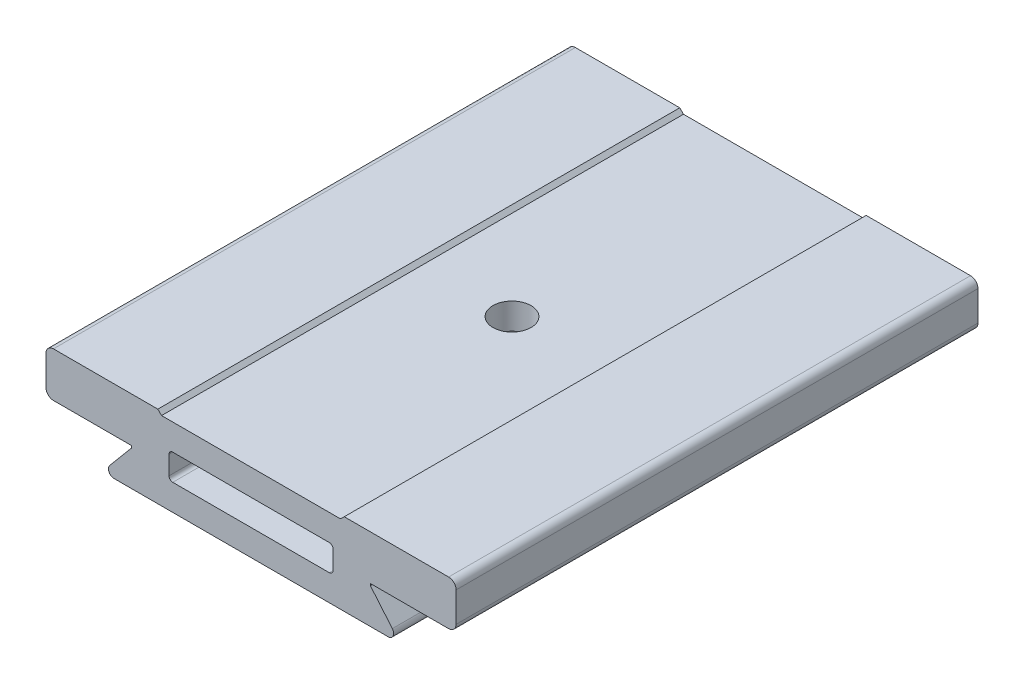
from build123d import *

# Parameters (mm, degrees)
SKETCH1_W           = 55
SKETCH1_H           = 11
BOSS_EXTRUDE1_DEPTH = 35
CUT_EXTRUDE1_DEPTH  = 71
FILLET1_R           = 1
CUT_EXTRUDE2_DEPTH  = 71
CUT_EXTRUDE3_DEPTH  = 71
CUT_EXTRUDE4_DEPTH  = 7
FILLET2_R           = 0.5
SKETCH6_R           = 2.5527
CUT_EXTRUDE5_DEPTH  = 5


with BuildPart() as part:
    # Sketch1 → Boss-Extrude1 (new body, symmetric)
    with BuildSketch(Plane.XY):
        Rectangle(SKETCH1_W, SKETCH1_H)
    extrude(amount=BOSS_EXTRUDE1_DEPTH, both=True)

    # Sketch2 → Cut-Extrude1 (cut, through all)
    with BuildSketch(Plane.XY.offset(35)):
        with BuildLine():
            Line((-27.5, -0.5), (-16, -0.5))
            Line((-16, -0.5), (-16, -0.75))
            Line((-16, -0.75), (-18.95187639, -4.267909293))
            ThreePointArc((-18.95187639, -4.267909293), (-19.057073898, -5.066963696), (-18.377343058, -5.5))
            Line((-18.377343058, -5.5), (-27.5, -5.5))
            Line((-27.5, -5.5), (-27.5, -0.5))
        make_face()
    cut_extrude1 = extrude(amount=-CUT_EXTRUDE1_DEPTH, mode=Mode.SUBTRACT)

    # Mirror1: Cut-Extrude1 across plane
    add(cut_extrude1.mirror(Plane(origin=(0, 0, 0), x_dir=(0, 0, 1), z_dir=(1, 0, 0))), mode=Mode.SUBTRACT)

    # Fillet1
    fillet1_edges = [part.edges().sort_by_distance(p)[0] for p in [
        (-27.5, -0.5, 0),
        (27.5, -0.5, 0),
        (-27.5, 5.5, 0),
        (27.5, 5.5, 0),
    ]]
    fillet(fillet1_edges, radius=FILLET1_R)

    # Sketch3 → Cut-Extrude2 (cut, through all)
    with BuildSketch(Plane.XY.offset(35)):
        Polygon((-12.5, 5.5), (0, 5.5), (0, 5), (-12, 5), align=None)
    cut_extrude2 = extrude(amount=-CUT_EXTRUDE2_DEPTH, mode=Mode.SUBTRACT)

    # Mirror2: Cut-Extrude2 across plane
    add(cut_extrude2.mirror(Plane(origin=(0, 0, 0), x_dir=(0, 0, 1), z_dir=(1, 0, 0))), mode=Mode.SUBTRACT)

    # Sketch4 → Cut-Extrude3 (cut, through all)
    with BuildSketch(Plane.XY.offset(35)):
        with BuildLine():
            Line((-11, 1.5), (11, 1.5))
            Line((11, 1.5), (11, -1.5))
            ThreePointArc((11, -1.5), (10.853553391, -1.853553391), (10.5, -2))
            Line((10.5, -2), (-10.5, -2))
            ThreePointArc((-10.5, -2), (-10.853553391, -1.853553391), (-11, -1.5))
            Line((-11, -1.5), (-11, 1.5))
        make_face()
    extrude(amount=-CUT_EXTRUDE3_DEPTH, mode=Mode.SUBTRACT)

    # Sketch5 → Cut-Extrude4 (cut)
    with BuildSketch(Plane.XZ.offset(5.5)):
        with BuildLine():
            Line((-8, 28.5), (8, 28.5))
            ThreePointArc((8, 28.5), (10.121320344, 27.621320344), (11, 25.5))
            Line((11, 25.5), (11, -25.5))
            ThreePointArc((11, -25.5), (10.121320344, -27.621320344), (8, -28.5))
            Line((8, -28.5), (-8, -28.5))
            ThreePointArc((-8, -28.5), (-10.121320344, -27.621320344), (-11, -25.5))
            Line((-11, -25.5), (-11, 25.5))
            ThreePointArc((-11, 25.5), (-10.121320344, 27.621320344), (-8, 28.5))
        make_face()
    extrude(amount=-CUT_EXTRUDE4_DEPTH, mode=Mode.SUBTRACT)

    # Fillet2
    fillet2_edges = [part.edges().sort_by_distance(p)[0] for p in [
        (-11, 1.5, 0),
        (11, 1.5, 0),
    ]]
    fillet(fillet2_edges, radius=FILLET2_R)

    # Sketch6 → Cut-Extrude5 (cut, through all)
    with BuildSketch(Plane.XZ.offset(-1.5)):
        Circle(SKETCH6_R)
    extrude(amount=-CUT_EXTRUDE5_DEPTH, mode=Mode.SUBTRACT)


solid = part.part
